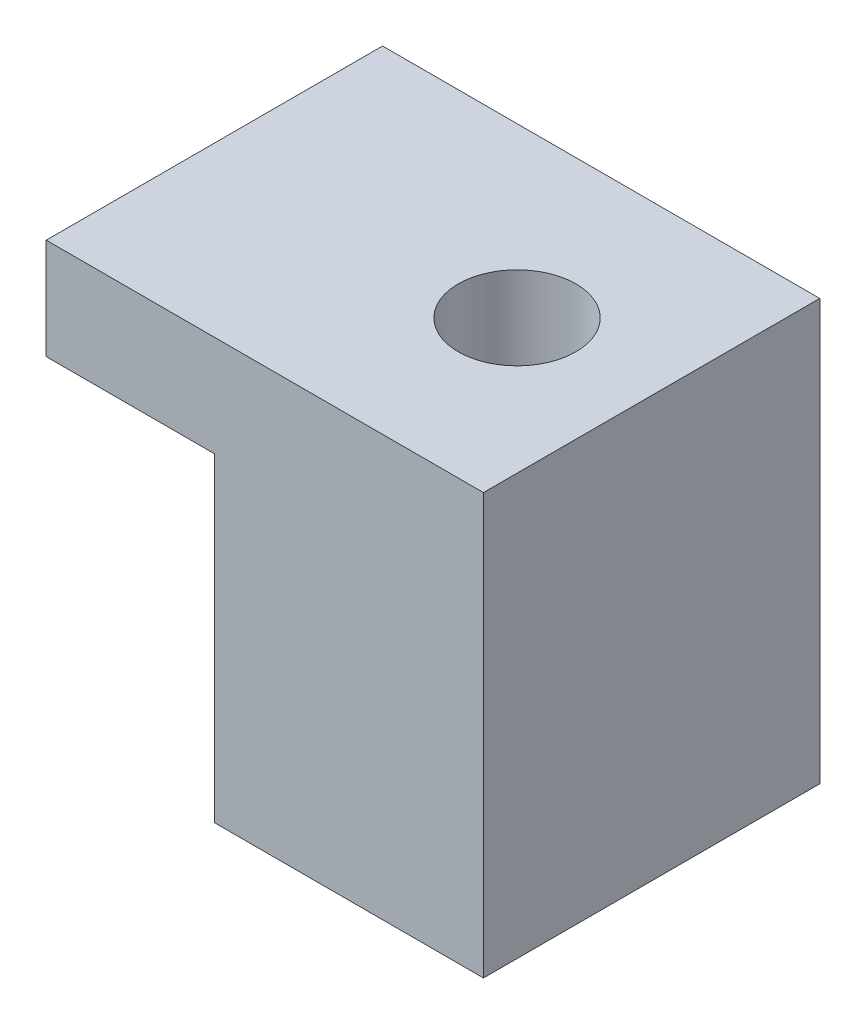
from build123d import *

# Parameters (mm, degrees)
EXTRUDE_1_DEPTH     = 10
SKETCH_2_R          = 1.75
CUT_EXTRUDE_1_DEPTH = 13.5


with BuildPart() as part:
    # ｽｹｯﾁ1 → ﾎﾞｽ - 押し出し1 (new body)
    with BuildSketch(Plane.XY):
        Polygon((0, 0), (0, 9.5), (-5, 9.5), (-5, 12.5), (8, 12.5), (8, 0), align=None)
    extrude(amount=EXTRUDE_1_DEPTH)

    # ｽｹｯﾁ2 → ｶｯﾄ - 押し出し1 (cut, through all)
    with BuildSketch(Plane.XZ):
        with Locations((4, 5)):
            Circle(SKETCH_2_R)
    extrude(amount=-CUT_EXTRUDE_1_DEPTH, mode=Mode.SUBTRACT)


solid = part.part
